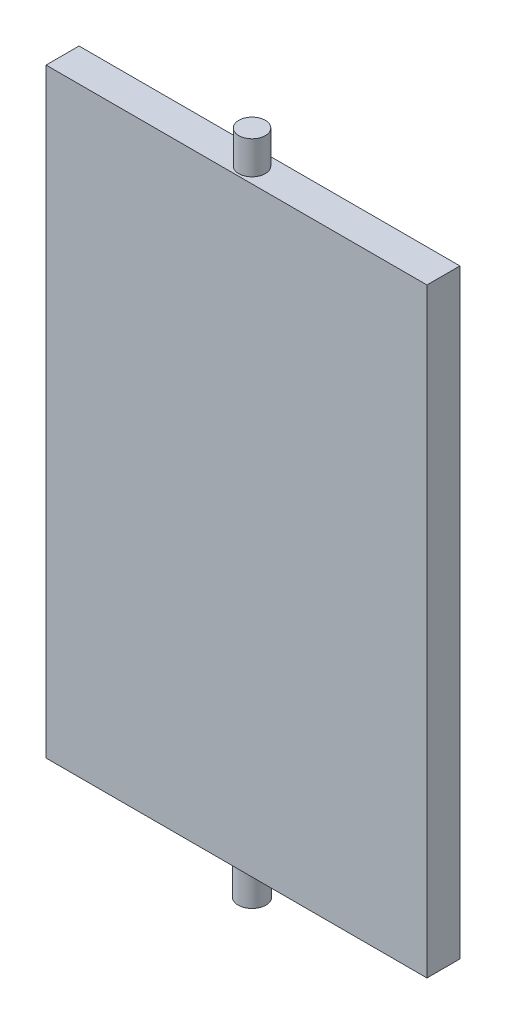
from build123d import *

# Parameters (mm, degrees)
SKETCH1_W           = 241
SKETCH1_H           = 374
BOSS_EXTRUDE1_DEPTH = 20
SKETCH5_R           = 8.426003706
BOSS_EXTRUDE3_DEPTH = 20
SKETCH6_W           = 241
SKETCH6_H           = 20
CUT_EXTRUDE1_DEPTH  = 5
SKETCH7_R           = 8.40478741
BOSS_EXTRUDE4_DEPTH = 20
SKETCH8_W           = 20
SKETCH8_H           = 369
CUT_EXTRUDE2_DEPTH  = 5
SKETCH9_W           = 20
SKETCH9_H           = 369
CUT_EXTRUDE3_DEPTH  = 5
SKETCH11_R          = 8.426003706
CUT_EXTRUDE4_DEPTH  = 10
SKETCH12_R          = 8.40478741
CUT_EXTRUDE5_DEPTH  = 10
SKETCH13_R          = 8.40478741
BOSS_EXTRUDE6_DEPTH = 10
SKETCH14_R          = 8.426003706
BOSS_EXTRUDE7_DEPTH = 10
SKETCH15_W          = 231
SKETCH15_H          = 20
CUT_EXTRUDE6_DEPTH  = 5
SKETCH16_R          = 8.05
BOSS_EXTRUDE8_DEPTH = 20


with BuildPart() as part:
    # Sketch1 → Boss-Extrude1 (new body)
    with BuildSketch(Plane.XY):
        with Locations((93.728999485, -168.226086957)):
            Rectangle(SKETCH1_W, SKETCH1_H)
    extrude(amount=BOSS_EXTRUDE1_DEPTH)

    # Sketch5 → Boss-Extrude3 (add)
    with BuildSketch(Plane.XZ.offset(355.226086957)):
        with Locations(Location((93.728999485, 10.577560917, 0), (0, 0, 90))):
            Circle(SKETCH5_R)
    extrude(amount=BOSS_EXTRUDE3_DEPTH)

    # Sketch6 → Cut-Extrude1 (cut)
    with BuildSketch(Plane(origin=(0, 18.773913043, 0), x_dir=(1, 0, 0), z_dir=(0, 1, 0))):
        with Locations((93.728999485, -10)):
            Rectangle(SKETCH6_W, SKETCH6_H)
    extrude(amount=-CUT_EXTRUDE1_DEPTH, mode=Mode.SUBTRACT)

    # Sketch7 → Boss-Extrude4 (add)
    with BuildSketch(Plane(origin=(0, 13.773913043, 0), x_dir=(1, 0, 0), z_dir=(0, 1, 0))):
        with Locations(Location((93.728999485, -10.486825902, 0), (0, 0, 270))):
            Circle(SKETCH7_R)
    extrude(amount=BOSS_EXTRUDE4_DEPTH)

    # Sketch8 → Cut-Extrude2 (cut)
    with BuildSketch(Plane.ZY.offset(26.771000515)):
        with Locations((10, -170.726086957)):
            Rectangle(SKETCH8_W, SKETCH8_H)
    extrude(amount=-CUT_EXTRUDE2_DEPTH, mode=Mode.SUBTRACT)

    # Sketch9 → Cut-Extrude3 (cut)
    with BuildSketch(Plane(origin=(214.228999485, 0, 0), x_dir=(0, 0, -1), z_dir=(1, 0, 0))):
        with Locations((-10, -170.726086957)):
            Rectangle(SKETCH9_W, SKETCH9_H)
    extrude(amount=-CUT_EXTRUDE3_DEPTH, mode=Mode.SUBTRACT)

    # Sketch11 → Cut-Extrude4 (cut)
    with BuildSketch(Plane.XZ.offset(375.226086957)):
        with Locations(Location((93.728999485, 10.577560917, 0), (0, 0, 90))):
            Circle(SKETCH11_R)
    extrude(amount=-CUT_EXTRUDE4_DEPTH, mode=Mode.SUBTRACT)

    # Sketch12 → Cut-Extrude5 (cut)
    with BuildSketch(Plane(origin=(0, 33.773913043, 0), x_dir=(1, 0, 0), z_dir=(0, 1, 0))):
        with Locations(Location((93.728999485, -10.486825902, 0), (0, 0, 270))):
            Circle(SKETCH12_R)
    extrude(amount=-CUT_EXTRUDE5_DEPTH, mode=Mode.SUBTRACT)

    # Sketch13 → Boss-Extrude6 (add)
    with BuildSketch(Plane(origin=(0, 23.773913043, 0), x_dir=(1, 0, 0), z_dir=(0, 1, 0))):
        with Locations(Location((93.728999485, -10.486825902, 0), (0, 0, 270))):
            Circle(SKETCH13_R)
    extrude(amount=BOSS_EXTRUDE6_DEPTH)

    # Sketch14 → Boss-Extrude7 (add)
    with BuildSketch(Plane.XZ.offset(365.226086957)):
        with Locations(Location((93.728999485, 10.577560917, 0), (0, 0, 90))):
            Circle(SKETCH14_R)
    extrude(amount=BOSS_EXTRUDE7_DEPTH)

    # Sketch15 → Cut-Extrude6 (cut)
    with BuildSketch(Plane(origin=(0, 13.773913043, 0), x_dir=(1, 0, 0), z_dir=(0, 1, 0))):
        with Locations((93.728999485, -10)):
            Rectangle(SKETCH15_W, SKETCH15_H)
    extrude(amount=-CUT_EXTRUDE6_DEPTH, mode=Mode.SUBTRACT)


with BuildPart() as body_2:
    # of the pieces the cut leaves, the one that is kept (cut_extrude6_keep)
    add(part.part.solids().sort_by_distance((-21.771000515, 8.773913043, 0))[0])

    # Sketch16 → Boss-Extrude8 (add)
    with BuildSketch(Plane(origin=(0, 8.773913043, 0), x_dir=(1, 0, 0), z_dir=(0, 1, 0))):
        with Locations(Location((93.728999485, -10.577560917, 0), (0, 0, 270))):
            Circle(SKETCH16_R)
    extrude(amount=BOSS_EXTRUDE8_DEPTH)


solid = body_2.part
